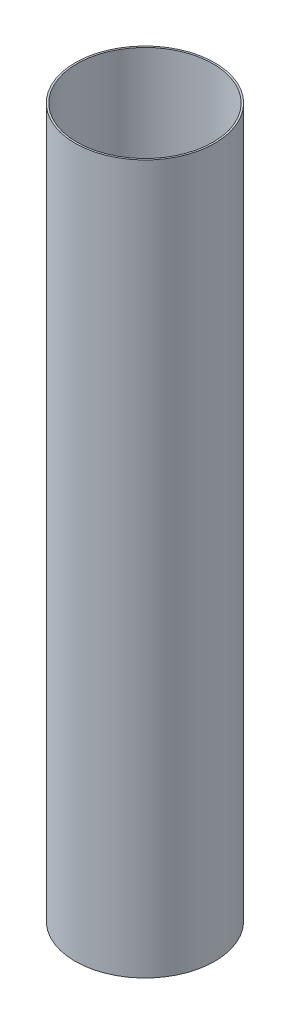
from build123d import *

# Parameters (mm, degrees)
SKETCH1_R           = 20
SKETCH1_R_2         = 19.5
BOSS_EXTRUDE1_DEPTH = 203


with BuildPart() as part:
    # Sketch1 → Boss-Extrude1 (new body)
    with BuildSketch(Plane(origin=(0, 0, 0), x_dir=(1, 0, 0), z_dir=(0, 1, 0))):
        Circle(SKETCH1_R)
        Circle(SKETCH1_R_2, mode=Mode.SUBTRACT)
    extrude(amount=BOSS_EXTRUDE1_DEPTH)


solid = part.part
